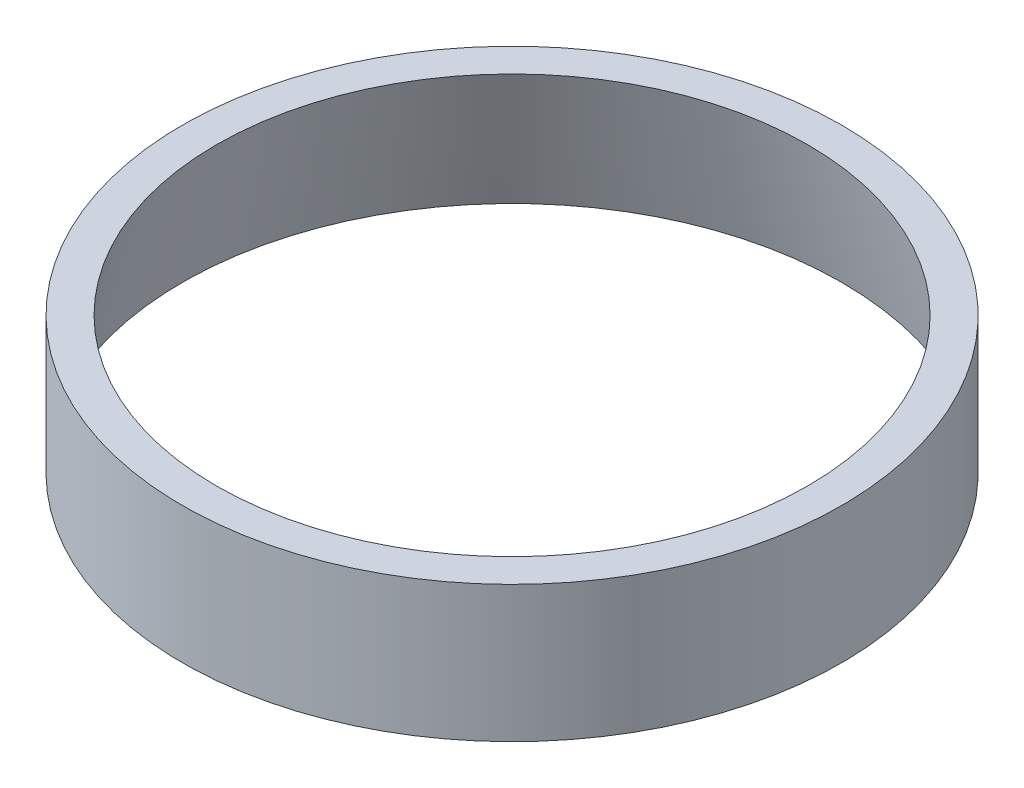
from build123d import *


with BuildPart() as part:
    # Sketch1 → Revolve1 (revolve)
    with BuildSketch(Plane.XY):
        Polygon((37.5, 0), (33.635415956, 15.5), (37.5, 15.5), align=None)
    revolve(axis=Axis((0, 0, 0), (0, 1, 0)))


solid = part.part
